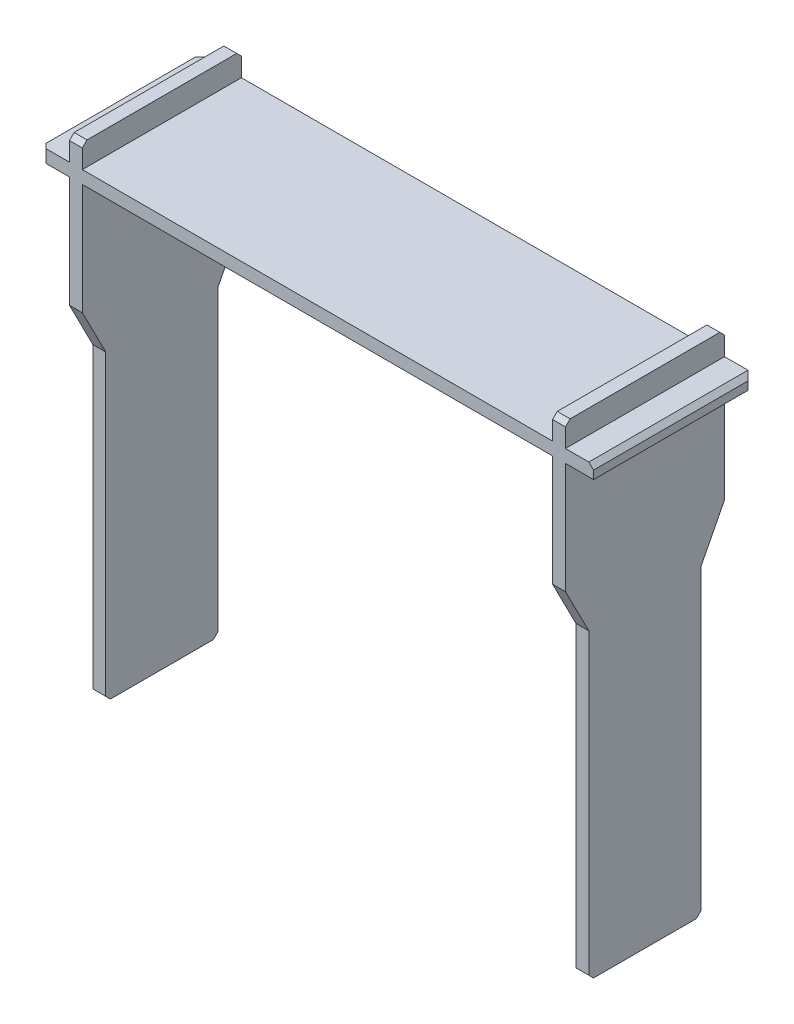
from build123d import *

# Parameters (mm, degrees)
SKETCH1_W           = 2.75
SKETCH1_H           = 5
SKETCH1_W_2         = 6
SKETCH1_H_2         = 2.75
SKETCH1_H_3         = 98.25
SKETCH1_W_3         = 100.5
BOSS_EXTRUDE1_DEPTH = 17
CUT_EXTRUDE1_DEPTH  = 113
CHAMFER1_SIZE       = 1


with BuildPart() as part:
    # Sketch1 → Boss-Extrude1 (new body, symmetric)
    with BuildSketch(Plane.XY):
        with Locations((-51.625, 3.875)):
            Rectangle(SKETCH1_W, SKETCH1_H)
        with Locations((-56, 0)):
            Rectangle(SKETCH1_W_2, SKETCH1_H_2)
        with Locations((-51.625, 0)):
            Rectangle(SKETCH1_W, SKETCH1_H_2)
        with Locations((-51.625, -50.5)):
            Rectangle(SKETCH1_W, SKETCH1_H_3)
        Rectangle(SKETCH1_W_3, SKETCH1_H_2)
        with Locations((51.625, 3.875)):
            Rectangle(SKETCH1_W, SKETCH1_H)
        with Locations((51.625, 0)):
            Rectangle(SKETCH1_W, SKETCH1_H_2)
        with Locations((56, 0)):
            Rectangle(SKETCH1_W_2, SKETCH1_H_2)
        with Locations((51.625, -50.5)):
            Rectangle(SKETCH1_W, SKETCH1_H_3)
    extrude(amount=BOSS_EXTRUDE1_DEPTH, both=True)

    # Sketch2 → Cut-Extrude1 (cut, through all)
    with BuildSketch(Plane(origin=(53, 0, 0), x_dir=(0, 0, -1), z_dir=(1, 0, 0))):
        Polygon((-12, -34.875), (-17, -25.125), (-17, -99.625), (-12, -99.625), align=None)
        Polygon((17, -99.625), (17, -25.125), (12, -34.875), (12, -99.625), align=None)
    extrude(amount=-CUT_EXTRUDE1_DEPTH, mode=Mode.SUBTRACT)

    # Chamfer1
    chamfer1_edges = [part.edges().sort_by_distance(p)[0] for p in [
        (-51.625, 6.375, 17),
        (51.625, -99.625, -12),
        (-59, 0, 17),
        (-51.625, 6.375, -17),
        (51.625, 6.375, -17),
        (59, 0, -17),
        (-59, 0, -17),
        (59, 1.375, 0),
        (51.625, 6.375, 17),
        (-51.625, -99.625, 12),
        (51.625, -99.625, 12),
        (-51.625, -99.625, -12),
    ]]
    chamfer(chamfer1_edges, length=CHAMFER1_SIZE)


solid = part.part
